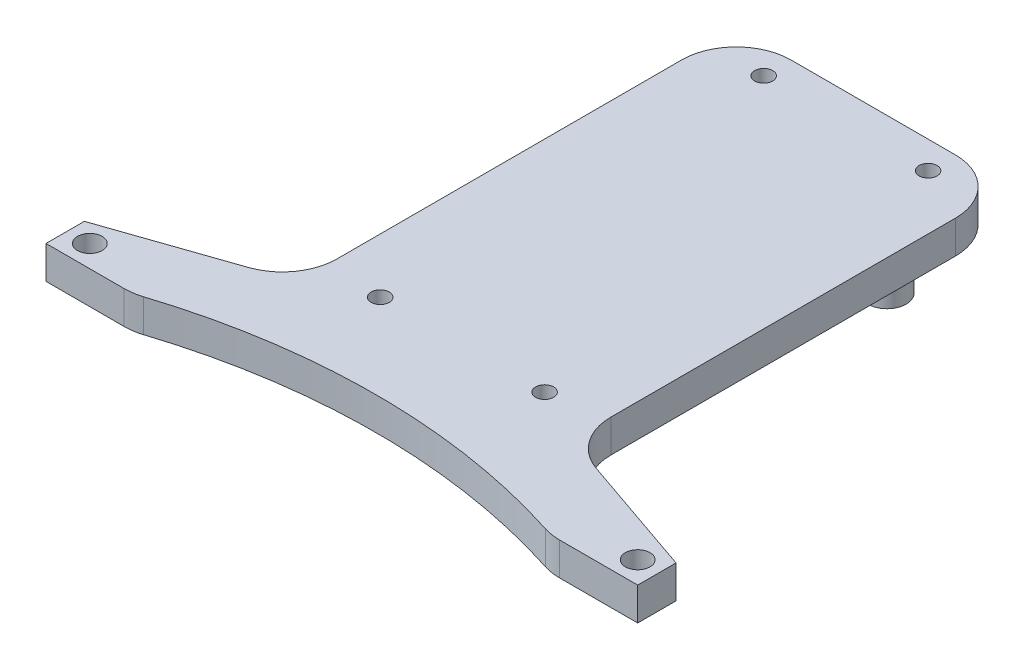
from build123d import *

# Parameters (mm, degrees)
SKETCH1_R               = 2.25
SKETCH1_R_2             = 1.65
BOSS_EXTRUDE1_DEPTH     = 6
CUT_EXTRUDE1_DEPTH      = 1
CUT_EXTRUDE1_DEPTH_BACK = 7
SKETCH3_R               = 3.5
BOSS_EXTRUDE2_DEPTH     = 7.1
CHAMFER1_SIZE           = 2
BOSS_EXTRUDE3_DEPTH     = 6
FILLET1_R               = 10


with BuildPart() as part:
    # Sketch1 → Boss-Extrude1 (new body)
    with BuildSketch(Plane(origin=(0, 0, 0), x_dir=(1, 0, 0), z_dir=(0, 1, 0))):
        Polygon((0, 0), (108, 0), (108, 6), (79, 16), (79, 96), (29, 96), (29, 16), (0, 6), align=None)
        with Locations((4, 3)):
            Circle(SKETCH1_R, mode=Mode.SUBTRACT)
        with Locations((104, 3)):
            Circle(SKETCH1_R, mode=Mode.SUBTRACT)
        with Locations((39, 91)):
            Circle(SKETCH1_R_2, mode=Mode.SUBTRACT)
        with Locations((69, 91)):
            Circle(SKETCH1_R_2, mode=Mode.SUBTRACT)
        with Locations((39, 21)):
            Circle(SKETCH1_R_2, mode=Mode.SUBTRACT)
        with Locations((69, 21)):
            Circle(SKETCH1_R_2, mode=Mode.SUBTRACT)
    extrude(amount=BOSS_EXTRUDE1_DEPTH)

    # Sketch2 → Cut-Extrude1 (cut, two sides)
    with BuildSketch(Plane(origin=(0, 6, 0), x_dir=(1, 0, 0), z_dir=(0, 1, 0))) as cut_extrude1_sk:
        with BuildLine():
            Line((19, 0), (89, 0))
            ThreePointArc((89, 0), (54, 5.217597168), (19, 0))
        make_face()
    extrude(amount=CUT_EXTRUDE1_DEPTH, mode=Mode.SUBTRACT)
    extrude(cut_extrude1_sk.sketch, amount=-CUT_EXTRUDE1_DEPTH_BACK, mode=Mode.SUBTRACT)

    # Sketch3 → Boss-Extrude2 (add)
    with BuildSketch(Plane.XZ):
        with Locations((36.5, -81)):
            Circle(SKETCH3_R)
        with Locations((71.5, -81)):
            Circle(SKETCH3_R)
    extrude(amount=BOSS_EXTRUDE2_DEPTH)

    # Chamfer1
    chamfer1_edges = [part.edges().sort_by_distance(p)[0] for p in [
        (33, 0, -81),
        (68, 0, -81),
    ]]
    chamfer(chamfer1_edges, length=CHAMFER1_SIZE)

    # Sketch4 → Boss-Extrude3 (add)
    with BuildSketch(Plane(origin=(0, 6, 0), x_dir=(1, 0, 0), z_dir=(0, 1, 0))):
        with BuildLine():
            Line((0, 0), (0, -1))
            Line((0, -1), (15.874355013, -1))
            ThreePointArc((15.874355013, -1), (17.433758893, -0.489314628), (19, 0))
            Line((19, 0), (0, 0))
        make_face()
        with BuildLine():
            Line((108, -1), (92.125644987, -1))
            ThreePointArc((92.125644987, -1), (90.566241107, -0.489314628), (89, 0))
            Line((89, 0), (108, 0))
            Line((108, 0), (108, -1))
        make_face()
    extrude(amount=-BOSS_EXTRUDE3_DEPTH)

    # Fillet1
    fillet1_edges = [part.edges().sort_by_distance(p)[0] for p in [
        (29, 3, -16),
        (29, 3, -96),
        (79, 3, -96),
        (79, 3, -16),
        (15.874355013, 3, 1),
        (92.125644987, 3, 1),
    ]]
    fillet(fillet1_edges, radius=FILLET1_R)


solid = part.part
